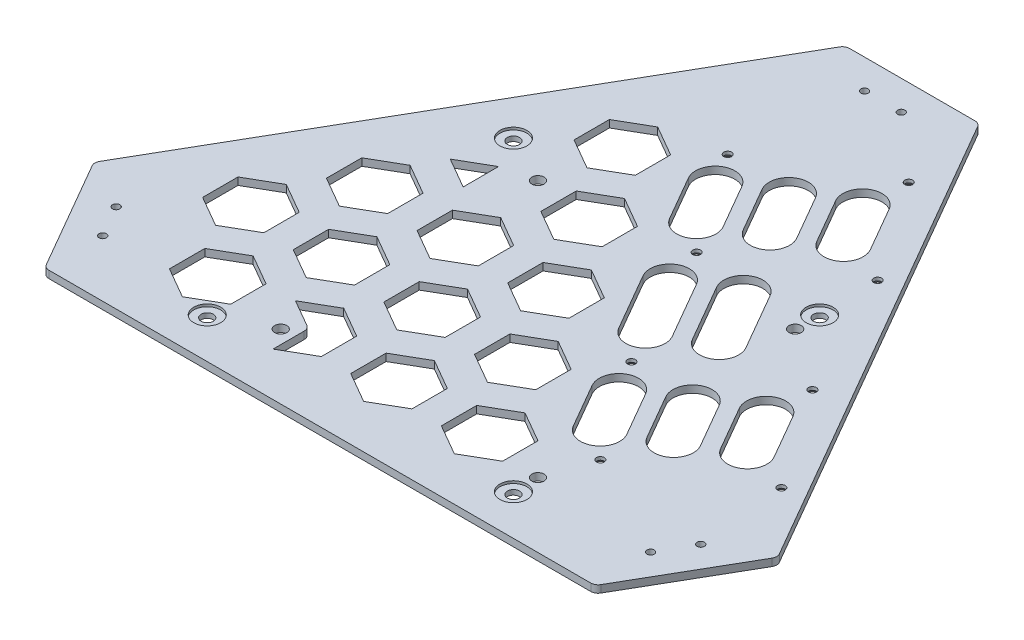
from build123d import *

# Parameters (mm, degrees)
EXTRUDE_1_DEPTH             = 3
CUT_EXTRUDE_1_DEPTH         = 4
CUT_EXTRUDE_2_DEPTH         = 4
CUT_EXTRUDE_3_DEPTH         = 4
CUT_EXTRUDE_4_DEPTH         = 4
CUT_EXTRUDE_5_DEPTH         = 4
CUT_EXTRUDE_6_DEPTH         = 4
CUT_EXTRUDE_7_DEPTH         = 4
CUT_EXTRUDE_8_DEPTH         = 4
CUT_EXTRUDE_9_DEPTH         = 4
CUT_EXTRUDE_10_DEPTH        = 4
CUT_EXTRUDE_11_DEPTH        = 4
CUT_EXTRUDE_12_DEPTH        = 4
CUT_EXTRUDE_13_DEPTH        = 4
CUT_EXTRUDE_14_DEPTH        = 4
CUT_EXTRUDE_15_DEPTH        = 4
CUT_EXTRUDE_16_DEPTH        = 4
CUT_EXTRUDE_17_DEPTH        = 4
CUT_EXTRUDE_18_DEPTH        = 4
CUT_EXTRUDE_19_DEPTH        = 4
CUT_EXTRUDE_20_DEPTH        = 4
CUT_EXTRUDE_21_DEPTH        = 4
CUT_EXTRUDE_22_DEPTH        = 4
HOLE_WIZARD_M3_1_AT_2_COUNT = 2
HOLE_WIZARD_M3_1_AT_2_PITCH = 54.1
HOLE_WIZARD_M3_1_AT_3_COUNT = 2
HOLE_WIZARD_M3_1_AT_3_PITCH = 49.800899411
HOLE_WIZARD_M3_1_AT_4_COUNT = 2
HOLE_WIZARD_M3_1_AT_4_PITCH = 70.527580294
HOLE_WIZARD_M3_1_AT_5_COUNT = 2
HOLE_WIZARD_M3_1_AT_5_PITCH = 107.36
HOLE_WIZARD_M3_1_AT_6_COUNT = 2
HOLE_WIZARD_M3_1_AT_6_PITCH = 120.220545771
HOLE_WIZARD_M3_1_AT_7_COUNT = 2
HOLE_WIZARD_M3_1_AT_7_PITCH = 157.050946968
HOLE_WIZARD_M3_1_AT_8_COUNT = 2
HOLE_WIZARD_M3_1_AT_8_PITCH = 164.799908809
HOLE_WIZARD_1_D             = 5
HOLE_WIZARD_1_DEPTH         = 3
HOLE_WIZARD_1_CBORE_D       = 11
HOLE_WIZARD_1_CBORE_DEPTH   = 1
HOLE_WIZARD_3_0_3_1_D       = 3
HOLE_WIZARD_3_0_3_1_DEPTH   = 3
HOLE_WIZARD_5_0_5_1_D       = 5
HOLE_WIZARD_5_0_5_1_DEPTH   = 3


with BuildPart() as part:
    # 草圖1 → 填料-伸長1 (new body)
    with BuildSketch(Plane.XZ.offset(3)):
        with BuildLine():
            Line((-138.752776596, 47.574772881), (-28.175426404, -143.950815819))
            ThreePointArc((-28.175426404, -143.950815819), (-27.077350192, -145.04889203), (-25.577350192, -145.450815819))
            Line((-25.577350192, -145.450815819), (25.577350192, -145.450815819))
            ThreePointArc((25.577350192, -145.450815819), (27.077350192, -145.04889203), (28.175426404, -143.950815819))
            Line((28.175426404, -143.950815819), (138.752776596, 47.574772881))
            ThreePointArc((138.752776596, 47.574772881), (139.154700385, 49.074772881), (138.752776596, 50.574772881))
            Line((138.752776596, 50.574772881), (113.175426404, 94.876042937))
            ThreePointArc((113.175426404, 94.876042937), (112.077350192, 95.974119149), (110.577350192, 96.376042937))
            Line((110.577350192, 96.376042937), (-110.577350192, 96.376042937))
            ThreePointArc((-110.577350192, 96.376042937), (-112.077350192, 95.974119149), (-113.175426404, 94.876042937))
            Line((-113.175426404, 94.876042937), (-138.752776596, 50.574772881))
            ThreePointArc((-138.752776596, 50.574772881), (-139.154700385, 49.074772881), (-138.752776596, 47.574772881))
        make_face()
    extrude(amount=-EXTRUDE_1_DEPTH)

    # 草圖2 → 除料-伸長1 (cut, through all)
    with BuildSketch(Plane.XZ.offset(3)):
        with BuildLine():
            Line((39.249745847, -96.769531884), (49.749745847, -78.582998404))
            ThreePointArc((49.749745847, -78.582998404), (46.821542617, -67.654795174), (35.893339386, -70.582998404))
            Line((35.893339386, -70.582998404), (25.393339386, -88.769531884))
            ThreePointArc((25.393339386, -88.769531884), (28.321542617, -99.697735114), (39.249745847, -96.769531884))
        make_face()
    extrude(amount=-CUT_EXTRUDE_1_DEPTH, mode=Mode.SUBTRACT)

    # 草圖3 → 除料-伸長2 (cut, through all)
    with BuildSketch(Plane.XZ.offset(3)):
        Polygon((-49.5, -71.296878365), (-37, -78.51375673), (-24.5, -71.296878365), (-24.5, -56.863121635), (-37, -49.64624327), (-49.5, -56.863121635), align=None)
    extrude(amount=-CUT_EXTRUDE_2_DEPTH, mode=Mode.SUBTRACT)

    # 草圖4 → 除料-伸長3 (cut, through all)
    with BuildSketch(Plane.XZ.offset(3)):
        with BuildLine():
            Line((92.929745847, -3.793044533), (103.429745847, 14.393488946))
            ThreePointArc((103.429745847, 14.393488946), (100.501542617, 25.321692176), (89.573339386, 22.393488946))
            Line((89.573339386, 22.393488946), (79.073339386, 4.206955467))
            ThreePointArc((79.073339386, 4.206955467), (82.001542617, -6.721247764), (92.929745847, -3.793044533))
        make_face()
    extrude(amount=-CUT_EXTRUDE_3_DEPTH, mode=Mode.SUBTRACT)

    # 草圖5 → 除料-伸長4 (cut, through all)
    with BuildSketch(Plane.XZ.offset(3)):
        with BuildLine():
            Line((73.877186964, 7.206955467), (84.377186964, 25.393488946))
            ThreePointArc((84.377186964, 25.393488946), (81.448983733, 36.321692176), (70.520780503, 33.393488946))
            Line((70.520780503, 33.393488946), (60.020780503, 15.206955467))
            ThreePointArc((60.020780503, 15.206955467), (62.948983733, 4.278752236), (73.877186964, 7.206955467))
        make_face()
    extrude(amount=-CUT_EXTRUDE_4_DEPTH, mode=Mode.SUBTRACT)

    # 草圖6 → 除料-伸長5 (cut, through all)
    with BuildSketch(Plane.XZ.offset(3)):
        with BuildLine():
            Line((45.537186964, -41.87936442), (59.037186964, -18.496678518))
            ThreePointArc((59.037186964, -18.496678518), (56.108983733, -7.568475287), (45.180780503, -10.496678518))
            Line((45.180780503, -10.496678518), (31.680780503, -33.87936442))
            ThreePointArc((31.680780503, -33.87936442), (34.608983733, -44.80756765), (45.537186964, -41.87936442))
        make_face()
    extrude(amount=-CUT_EXTRUDE_5_DEPTH, mode=Mode.SUBTRACT)

    # 草圖7 → 除料-伸長6 (cut, through all)
    with BuildSketch(Plane.XZ.offset(3)):
        with BuildLine():
            Line((26.484628081, -30.87936442), (39.984628081, -7.496678518))
            ThreePointArc((39.984628081, -7.496678518), (37.05642485, 3.431524713), (26.12822162, 0.503321482))
            Line((26.12822162, 0.503321482), (12.62822162, -22.87936442))
            ThreePointArc((12.62822162, -22.87936442), (15.55642485, -33.80756765), (26.484628081, -30.87936442))
        make_face()
    extrude(amount=-CUT_EXTRUDE_6_DEPTH, mode=Mode.SUBTRACT)

    # 草圖8 → 除料-伸長7 (cut, through all)
    with BuildSketch(Plane.XZ.offset(3)):
        with BuildLine():
            Line((54.824628081, 18.206955467), (65.324628081, 36.393488946))
            ThreePointArc((65.324628081, 36.393488946), (62.39642485, 47.321692176), (51.46822162, 44.393488946))
            Line((51.46822162, 44.393488946), (40.96822162, 26.206955467))
            ThreePointArc((40.96822162, 26.206955467), (43.89642485, 15.278752236), (54.824628081, 18.206955467))
        make_face()
    extrude(amount=-CUT_EXTRUDE_7_DEPTH, mode=Mode.SUBTRACT)

    # 草圖9 → 除料-伸長8 (cut, through all)
    with BuildSketch(Plane.XZ.offset(3)):
        Polygon((-12.5, -7.216878365), (0, -14.43375673), (12.5, -7.216878365), (12.5, 7.216878365), (0, 14.43375673), (-12.5, 7.216878365), align=None)
    extrude(amount=-CUT_EXTRUDE_8_DEPTH, mode=Mode.SUBTRACT)

    # 草圖10 → 除料-伸長9 (cut, through all)
    with BuildSketch(Plane.XZ.offset(3)):
        Polygon((-49.5, -7.216878365), (-37, -14.43375673), (-24.5, -7.216878365), (-24.5, 7.216878365), (-37, 14.43375673), (-49.5, 7.216878365), align=None)
    extrude(amount=-CUT_EXTRUDE_9_DEPTH, mode=Mode.SUBTRACT)

    # 草圖11 → 除料-伸長10 (cut, through all)
    with BuildSketch(Plane.XZ.offset(3)):
        Polygon((-86.5, -7.216878365), (-74, -14.43375673), (-61.5, -7.216878365), (-61.5, 7.216878365), (-74, 14.43375673), (-86.5, 7.216878365), align=None)
    extrude(amount=-CUT_EXTRUDE_10_DEPTH, mode=Mode.SUBTRACT)

    # 草圖12 → 除料-伸長11 (cut, through all)
    with BuildSketch(Plane.XZ.offset(3)):
        Polygon((-18.5, -46.47081679), (-6, -39.253938425), (-6, -24.820181695), (-18.5, -17.60330333), (-31, -24.820181695), (-31, -39.253938425), align=None)
    extrude(amount=-CUT_EXTRUDE_11_DEPTH, mode=Mode.SUBTRACT)

    # 草圖13 → 除料-伸長12 (cut, through all)
    with BuildSketch(Plane.XZ.offset(3)):
        Polygon((18.5, 17.60918321), (31, 24.826061575), (31, 39.259818305), (18.5, 46.47669667), (6, 39.259818305), (6, 24.826061575), align=None)
    extrude(amount=-CUT_EXTRUDE_12_DEPTH, mode=Mode.SUBTRACT)

    # 草圖14 → 除料-伸長13 (cut, through all)
    with BuildSketch(Plane.XZ.offset(3)):
        Polygon((-18.5, 17.60918321), (-6, 24.826061575), (-6, 39.259818305), (-18.5, 46.47669667), (-31, 39.259818305), (-31, 24.826061575), align=None)
    extrude(amount=-CUT_EXTRUDE_13_DEPTH, mode=Mode.SUBTRACT)

    # 草圖15 → 除料-伸長14 (cut, through all)
    with BuildSketch(Plane.XZ.offset(3)):
        Polygon((-55.5, 17.60918321), (-43, 24.826061575), (-43, 39.259818305), (-55.5, 46.47669667), (-68, 39.259818305), (-68, 24.826061575), align=None)
    extrude(amount=-CUT_EXTRUDE_14_DEPTH, mode=Mode.SUBTRACT)

    # 草圖16 → 除料-伸長15 (cut, through all)
    with BuildSketch(Plane.XZ.offset(3)):
        Polygon((-92.5, 17.60918321), (-80, 24.826061575), (-80, 39.259818305), (-92.5, 46.47669667), (-105, 39.259818305), (-105, 24.826061575), align=None)
    extrude(amount=-CUT_EXTRUDE_15_DEPTH, mode=Mode.SUBTRACT)

    # 草圖17 → 除料-伸長16 (cut, through all)
    with BuildSketch(Plane.XZ.offset(3)):
        Polygon((-74, 49.64624327), (-61.5, 56.863121635), (-61.5, 71.296878365), (-74, 78.51375673), (-86.5, 71.296878365), (-86.5, 56.863121635), align=None)
    extrude(amount=-CUT_EXTRUDE_16_DEPTH, mode=Mode.SUBTRACT)

    # 草圖18 → 除料-伸長17 (cut, through all)
    with BuildSketch(Plane.XZ.offset(3)):
        with BuildLine():
            Line((-49.5, 56.863121635), (-37, 49.64624327))
            Line((-37, 49.64624327), (-24.5, 56.863121635))
            Line((-24.5, 56.863121635), (-24.5, 71.296878365))
            Line((-24.5, 71.296878365), (-37, 78.51375673))
            Line((-37, 78.51375673), (-37, 65.812050808))
            ThreePointArc((-37, 65.812050808), (-37.401923789, 64.312050808), (-38.5, 63.213974596))
            Line((-38.5, 63.213974596), (-49.5, 56.863121635))
        make_face()
    extrude(amount=-CUT_EXTRUDE_17_DEPTH, mode=Mode.SUBTRACT)

    # 草圖19 → 除料-伸長18 (cut, through all)
    with BuildSketch(Plane.XZ.offset(3)):
        Polygon((-12.5, 56.863121635), (0, 49.64624327), (12.5, 56.863121635), (12.5, 71.296878365), (0, 78.51375673), (-12.5, 71.296878365), align=None)
    extrude(amount=-CUT_EXTRUDE_18_DEPTH, mode=Mode.SUBTRACT)

    # 草圖20 → 除料-伸長19 (cut, through all)
    with BuildSketch(Plane.XZ.offset(3)):
        Polygon((24.5, 56.863121635), (37, 49.64624327), (49.5, 56.863121635), (49.5, 71.296878365), (37, 78.51375673), (24.5, 71.296878365), align=None)
    extrude(amount=-CUT_EXTRUDE_19_DEPTH, mode=Mode.SUBTRACT)

    # 草圖21 → 除料-伸長20 (cut, through all)
    with BuildSketch(Plane.XZ.offset(3)):
        with BuildLine():
            Line((20.197186964, -85.769531884), (30.697186964, -67.582998404))
            ThreePointArc((30.697186964, -67.582998404), (27.768983733, -56.654795174), (16.840780503, -59.582998404))
            Line((16.840780503, -59.582998404), (6.340780503, -77.769531884))
            ThreePointArc((6.340780503, -77.769531884), (9.268983733, -88.697735114), (20.197186964, -85.769531884))
        make_face()
    extrude(amount=-CUT_EXTRUDE_20_DEPTH, mode=Mode.SUBTRACT)

    # 草圖22 → 除料-伸長21 (cut, through all)
    with BuildSketch(Plane.XZ.offset(3)):
        with BuildLine():
            Line((1.144628081, -74.769531884), (11.644628081, -56.582998404))
            ThreePointArc((11.644628081, -56.582998404), (8.71642485, -45.654795174), (-2.21177838, -48.582998404))
            Line((-2.21177838, -48.582998404), (-12.71177838, -66.769531884))
            ThreePointArc((-12.71177838, -66.769531884), (-9.78357515, -77.697735114), (1.144628081, -74.769531884))
        make_face()
    extrude(amount=-CUT_EXTRUDE_21_DEPTH, mode=Mode.SUBTRACT)

    # 草圖23 → 除料-伸長22 (cut, through all)
    with BuildSketch(Plane(origin=(0, 0, 0), x_dir=(-1, 0, 0), z_dir=(0, 1, 0))):
        Polygon((68, -24.820181695), (55.5, -17.60330333), (55.5, -32.03706006), align=None)
    extrude(amount=-CUT_EXTRUDE_22_DEPTH, mode=Mode.SUBTRACT)

    # 草圖24 → M3 平頭機械螺釘的錐孔1 (revolve, cut)
    with BuildSketch(Plane(origin=(68.933923912, -3, 50.844972706), x_dir=(0, 0, -1), z_dir=(1, 0, 0))):
        Polygon((0, 0), (0, 3), (1.6, 3), (1.6, 1.7), (3.3, 0), align=None)
    hole_wizard_m3_1 = revolve(axis=Axis((68.933923912, -9.35, 50.844972706), (0, 1, 0)), mode=Mode.SUBTRACT)

    # M3 平頭機械螺釘的錐孔1 at 2: M3 平頭機械螺釘的錐孔1 ×2
    with Locations(*[Vector(0.866025403, 0, -0.500000002) * (i * HOLE_WIZARD_M3_1_AT_2_PITCH) for i in range(1, HOLE_WIZARD_M3_1_AT_2_COUNT)]):
        add(hole_wizard_m3_1, mode=Mode.SUBTRACT)

    # M3 平頭機械螺釘的錐孔1 at 3: M3 平頭機械螺釘的錐孔1 ×2
    with Locations(*[Vector(-0.567943589, 0, -0.823067482) * (i * HOLE_WIZARD_M3_1_AT_3_PITCH) for i in range(1, HOLE_WIZARD_M3_1_AT_3_COUNT)]):
        add(hole_wizard_m3_1, mode=Mode.SUBTRACT)

    # M3 平頭機械螺釘的錐孔1 at 4: M3 平頭機械螺釘的錐孔1 ×2
    with Locations(*[Vector(0.263271088, 0, -0.964721895) * (i * HOLE_WIZARD_M3_1_AT_4_PITCH) for i in range(1, HOLE_WIZARD_M3_1_AT_4_COUNT)]):
        add(hole_wizard_m3_1, mode=Mode.SUBTRACT)

    # M3 平頭機械螺釘的錐孔1 at 5: M3 平頭機械螺釘的錐孔1 ×2
    with Locations(*[Vector(-0.5, 0, -0.866025404) * (i * HOLE_WIZARD_M3_1_AT_5_PITCH) for i in range(1, HOLE_WIZARD_M3_1_AT_5_COUNT)]):
        add(hole_wizard_m3_1, mode=Mode.SUBTRACT)

    # M3 平頭機械螺釘的錐孔1 at 6: M3 平頭機械螺釘的錐孔1 ×2
    with Locations(*[Vector(-0.05679583, 0, -0.998385814) * (i * HOLE_WIZARD_M3_1_AT_6_PITCH) for i in range(1, HOLE_WIZARD_M3_1_AT_6_COUNT)]):
        add(hole_wizard_m3_1, mode=Mode.SUBTRACT)

    # M3 平頭機械螺釘的錐孔1 at 7: M3 平頭機械螺釘的錐孔1 ×2
    with Locations(*[Vector(-0.521894984, 0, -0.853009745) * (i * HOLE_WIZARD_M3_1_AT_7_PITCH) for i in range(1, HOLE_WIZARD_M3_1_AT_7_COUNT)]):
        add(hole_wizard_m3_1, mode=Mode.SUBTRACT)

    # M3 平頭機械螺釘的錐孔1 at 8: M3 平頭機械螺釘的錐孔1 ×2
    with Locations(*[Vector(-0.213059142, 0, -0.977039304) * (i * HOLE_WIZARD_M3_1_AT_8_PITCH) for i in range(1, HOLE_WIZARD_M3_1_AT_8_COUNT)]):
        add(hole_wizard_m3_1, mode=Mode.SUBTRACT)

    # 鑽孔1
    with Locations(Plane(origin=(0, 0, 0), x_dir=(1, 0, 0), z_dir=(0, 1, 0))):
        with Locations((62.5, 45.123957063), (-62.5, -79.876042937), (62.5, -79.876042937), (-62.5, 45.123957063)):
            CounterBoreHole(HOLE_WIZARD_1_D / 2, HOLE_WIZARD_1_CBORE_D / 2, HOLE_WIZARD_1_CBORE_DEPTH, depth=HOLE_WIZARD_1_DEPTH)

    # Ø3.0 (3) 直徑孔1
    with Locations(Plane(origin=(0, 0, 0), x_dir=(1, 0, 0), z_dir=(0, 1, 0))):
        with Locations((-119.321796655, -60.230217381), (-111.821796655, -73.220598438), (7.5, 133.450815819), (-7.5, 133.450815819), (119.321796655, -60.230217381), (111.821796655, -73.220598438)):
            Hole(HOLE_WIZARD_3_0_3_1_D / 2, depth=HOLE_WIZARD_3_0_3_1_DEPTH)

    # Ø5.0 (5) 直徑孔1
    with Locations(Plane(origin=(0, 0, 0), x_dir=(1, 0, 0), z_dir=(0, 1, 0))):
        with Locations((-42.5, 35.123957063), (62.5, 35.123957063), (62.5, -69.876042937), (-42.5, -69.876042937)):
            Hole(HOLE_WIZARD_5_0_5_1_D / 2, depth=HOLE_WIZARD_5_0_5_1_DEPTH)


solid = part.part
